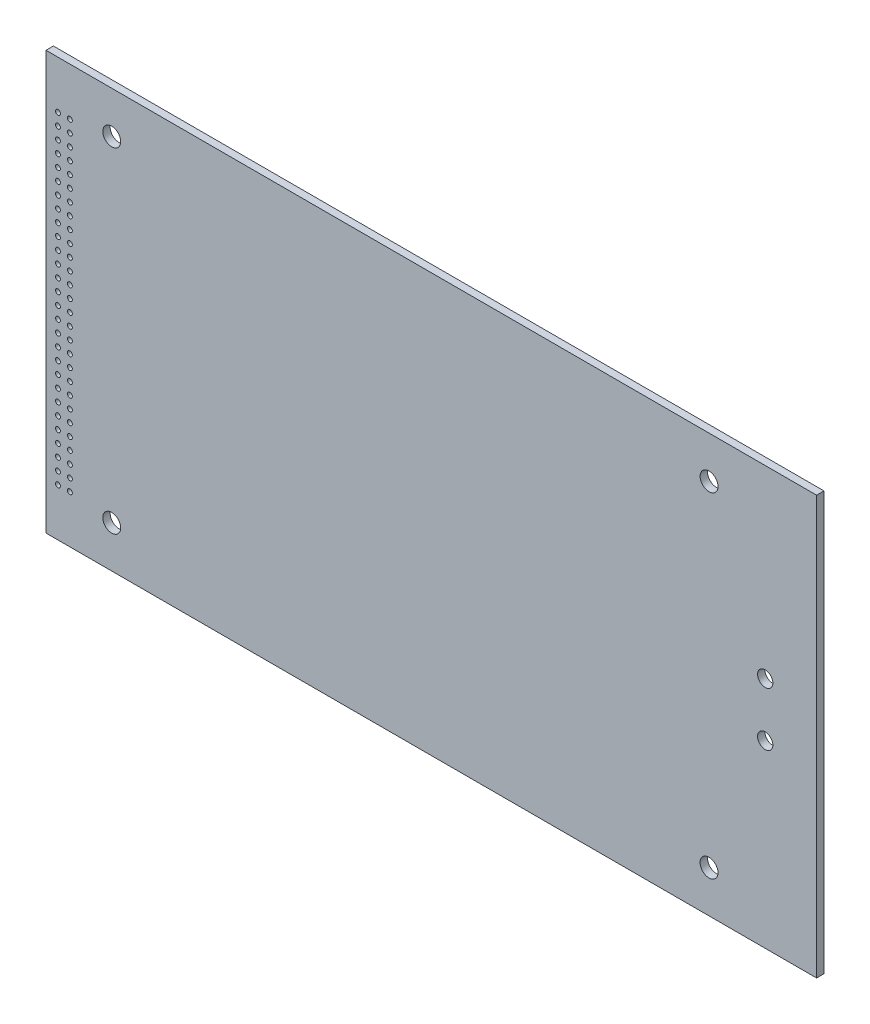
from build123d import *

# Parameters (mm, degrees)
SKETCH1_W                     = 163.83
SKETCH1_H                     = 88.9
EXTRUDE1_DEPTH                = 1.5748
SKETCH3_R                     = 1.6256
CUT_EXTRUDE2_DEPTH            = 10
SKETCH4_R                     = 1.905
MOUNT_HOLES_DEPTH             = 10
MOUNT_HOLE_PATTERN_COUNT      = 2
MOUNT_HOLE_PATTERN_PITCH      = 71.12
MOUNT_HOLE_PATTERN_COUNT_DIR2 = 2
MOUNT_HOLE_PATTERN_PITCH_DIR2 = 127
MOUNT_PIN_HOLES_R             = 0.52
CONNECTOR_PIN_1_DEPTH         = 2.54
LPATTERN1_COUNT               = 28
LPATTERN1_PITCH               = 2.54
LPATTERN1_COUNT_DIR2          = 2
LPATTERN1_PITCH_DIR2          = 2.54


with BuildPart() as part:
    # Sketch1 → Extrude1 (new body)
    with BuildSketch(Plane.XY):
        with Locations((81.915, -44.45)):
            Rectangle(SKETCH1_W, SKETCH1_H)
    extrude(amount=EXTRUDE1_DEPTH)

    # Sketch3 → Cut-Extrude2 (cut)
    with BuildSketch(Plane.XY.offset(1.5748)):
        with Locations((152.908, -50.673)):
            Circle(SKETCH3_R)
        with Locations((152.908, -39.243)):
            Circle(SKETCH3_R)
    extrude(amount=-CUT_EXTRUDE2_DEPTH, mode=Mode.SUBTRACT)

    # Sketch4 → Mount Holes (cut)
    with BuildSketch(Plane.XY.offset(1.5748)):
        with Locations((13.97, -80.01)):
            Circle(SKETCH4_R)
    mount_holes = extrude(amount=-MOUNT_HOLES_DEPTH, mode=Mode.SUBTRACT)

    # Mount Hole Pattern: Mount Holes 2 × 2
    with Locations(*[(j * MOUNT_HOLE_PATTERN_PITCH_DIR2, i * MOUNT_HOLE_PATTERN_PITCH, 0) for i in range(MOUNT_HOLE_PATTERN_COUNT) for j in range(MOUNT_HOLE_PATTERN_COUNT_DIR2) if (i, j) != (0, 0)]):
        add(mount_holes, mode=Mode.SUBTRACT)

    # Mount pin holes → Connector Pin 1 (cut)
    with BuildSketch(Plane.XY.offset(1.5748)):
        with Locations((2.54, -78.74)):
            Circle(MOUNT_PIN_HOLES_R)
    connector_pin_1 = extrude(amount=-CONNECTOR_PIN_1_DEPTH, mode=Mode.SUBTRACT)

    # LPattern1: Connector Pin 1 28 × 2
    with Locations(*[(j * LPATTERN1_PITCH_DIR2, i * LPATTERN1_PITCH, 0) for i in range(LPATTERN1_COUNT) for j in range(LPATTERN1_COUNT_DIR2) if (i, j) != (0, 0)]):
        add(connector_pin_1, mode=Mode.SUBTRACT)


solid = part.part
